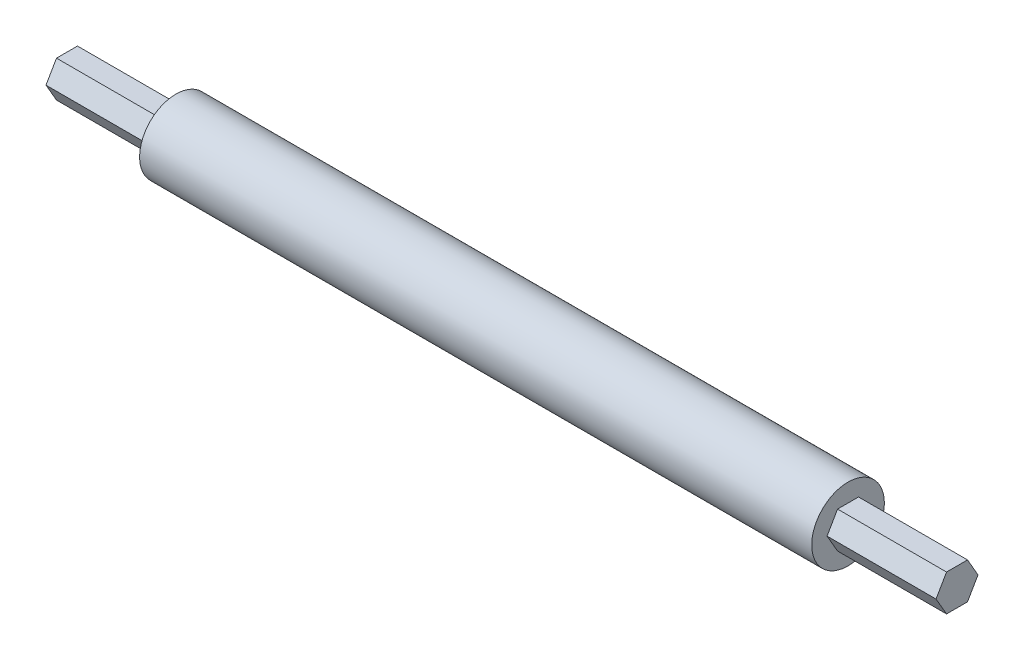
from build123d import *

# Parameters (mm, degrees)
BOSS_EXTRUDE1_DEPTH = 155.575
SKETCH3_R           = 12.7
BOSS_EXTRUDE2_DEPTH = 117.475


with BuildPart() as part:
    # Sketch1 → Boss-Extrude1 (new body, symmetric)
    with BuildSketch(Plane(origin=(0, 0, 0), x_dir=(0, 0, -1), z_dir=(1, 0, 0))):
        Polygon((3.666174209, 6.35), (-3.666174209, 6.35), (-7.332348419, 0), (-3.666174209, -6.35), (3.666174209, -6.35), (7.332348419, 0), align=None)
    extrude(amount=BOSS_EXTRUDE1_DEPTH, both=True)

    # Sketch3 → Boss-Extrude2 (add, symmetric)
    with BuildSketch(Plane(origin=(0, 0, 0), x_dir=(0, 0, -1), z_dir=(1, 0, 0))):
        Circle(SKETCH3_R)
    extrude(amount=BOSS_EXTRUDE2_DEPTH, both=True)


solid = part.part
